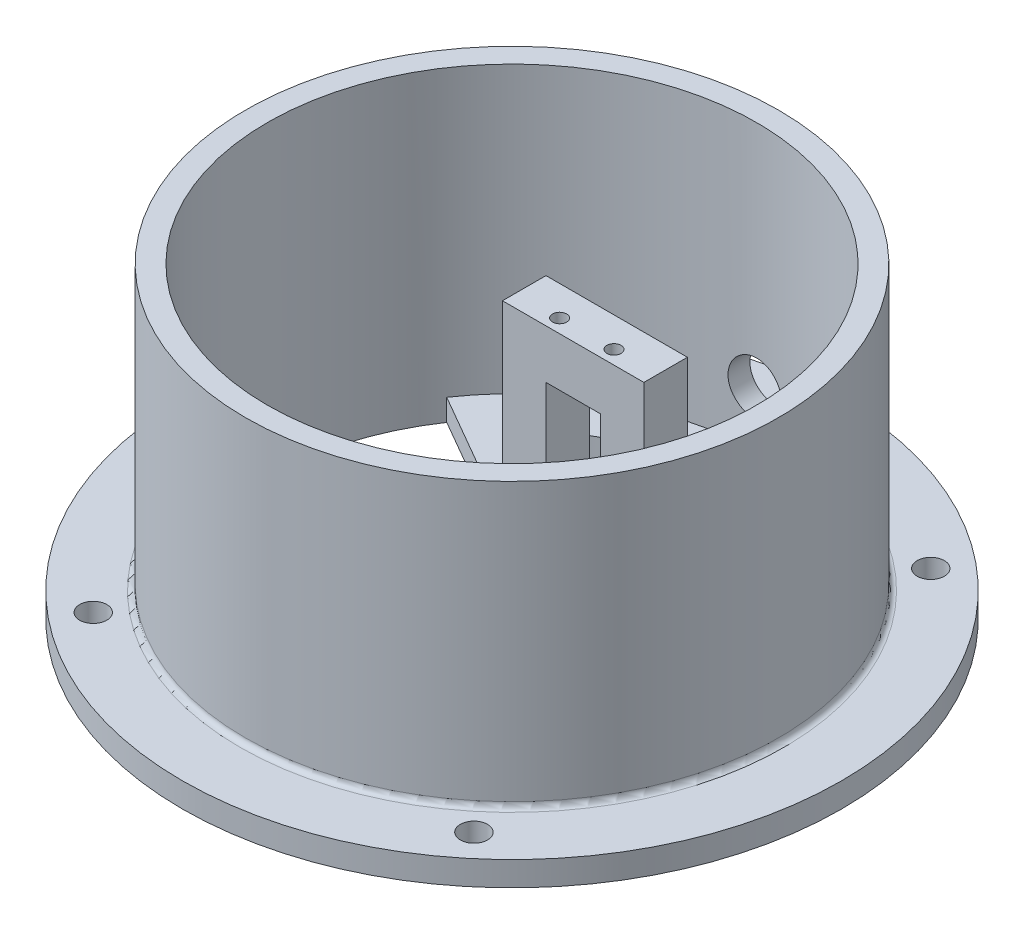
from build123d import *

# Parameters (mm, degrees)
SKETCH2_R           = 60.625
SKETCH2_R_2         = 45
BOSS_EXTRUDE1_DEPTH = 4.5
SKETCH3_R           = 49
SKETCH3_R_2         = 45
BOSS_EXTRUDE2_DEPTH = 52
SKETCH4_W           = 13.25
SKETCH4_H           = 8
SKETCH4_W_2         = 8
SKETCH4_H_2         = 38.5
BOSS_EXTRUDE3_DEPTH = 13
SKETCH5_W           = 10
SKETCH5_H           = 20
CUT_EXTRUDE1_DEPTH  = 26
SKETCH6_R           = 5
CUT_EXTRUDE2_DEPTH  = 50.375
SKETCH7_R           = 1.3
CUT_EXTRUDE3_DEPTH  = 7.2
BOSS_EXTRUDE4_DEPTH = 4
FILLET1_R           = 1
SKETCH9_R           = 2.5
CUT_EXTRUDE4_DEPTH  = 5.5000001


with BuildPart() as part:
    # Sketch2 → Boss-Extrude1 (new body)
    with BuildSketch(Plane(origin=(0, 0, 0), x_dir=(1, 0, 0), z_dir=(0, 1, 0))):
        Circle(SKETCH2_R)
        Circle(SKETCH2_R_2, mode=Mode.SUBTRACT)
    extrude(amount=BOSS_EXTRUDE1_DEPTH)

    # Sketch3 → Boss-Extrude2 (add)
    with BuildSketch(Plane(origin=(0, 4.5, 0), x_dir=(1, 0, 0), z_dir=(0, 1, 0))):
        Circle(SKETCH3_R)
        Circle(SKETCH3_R_2, mode=Mode.SUBTRACT)
    extrude(amount=BOSS_EXTRUDE2_DEPTH)

    # Sketch4 → Boss-Extrude3 (add, symmetric)
    with BuildSketch(Plane(origin=(0, 0, 0), x_dir=(0, 0, -1), z_dir=(1, 0, 0))):
        Polygon((-31.75, 30.5), (-45, 30.5), (-45, 17.25), align=None)
        with Locations((-38.375, 34.5)):
            Rectangle(SKETCH4_W, SKETCH4_H)
        with Locations((15.25, 19.25)):
            Rectangle(SKETCH4_W_2, SKETCH4_H_2)
    extrude(amount=BOSS_EXTRUDE3_DEPTH, both=True)

    # Sketch5 → Cut-Extrude1 (cut)
    with BuildSketch(Plane.XY):
        with Locations((0, 19.5)):
            Rectangle(SKETCH5_W, SKETCH5_H)
    extrude(amount=-CUT_EXTRUDE1_DEPTH, mode=Mode.SUBTRACT)

    # Sketch6 → Cut-Extrude2 (cut, through all)
    with BuildSketch(Plane.XY.offset(-11.25)):
        with Locations((0, 14)):
            Circle(SKETCH6_R)
    extrude(amount=-CUT_EXTRUDE2_DEPTH, mode=Mode.SUBTRACT)

    # Sketch7 → Cut-Extrude3 (cut)
    with BuildSketch(Plane(origin=(0, 38.5, 0), x_dir=(1, 0, 0), z_dir=(0, 1, 0))):
        with Locations((-5, 13.75)):
            Circle(SKETCH7_R)
        with Locations((5, 13.75)):
            Circle(SKETCH7_R)
        with Locations((-5, -34.25)):
            Circle(SKETCH7_R)
        with Locations((5, -34.25)):
            Circle(SKETCH7_R)
    extrude(amount=-CUT_EXTRUDE3_DEPTH, mode=Mode.SUBTRACT)

    # Sketch8 → Boss-Extrude4 (add)
    with BuildSketch(Plane.XZ):
        with BuildLine():
            Line((13, -11.25), (-13, -11.25))
            Line((-13, -11.25), (-37.248431585, -25.249838503))
            ThreePointArc((-37.248431585, -25.249838503), (0, -45), (37.248431585, -25.249838503))
            Line((37.248431585, -25.249838503), (13, -11.25))
        make_face()
        with BuildLine():
            Line((-19.516660498, -24.25), (-24.906460381, -27.361802413))
            ThreePointArc((-24.906460381, -27.361802413), (0, -37), (24.906460381, -27.361802413))
            Line((24.906460381, -27.361802413), (19.516660498, -24.25))
            Line((19.516660498, -24.25), (-19.516660498, -24.25))
        make_face(mode=Mode.SUBTRACT)
    extrude(amount=-BOSS_EXTRUDE4_DEPTH)

    # Fillet1
    fillet1_edges = [part.edges().sort_by_distance(p)[0] for p in [
        (-49, 4.5, 0),
    ]]
    fillet(fillet1_edges, radius=FILLET1_R)

    # Sketch9 → Cut-Extrude4 (cut, through all)
    with BuildSketch(Plane(origin=(0, 4.5, 0), x_dir=(1, 0, 0), z_dir=(0, 1, 0))):
        with Locations((35, 42)):
            Circle(SKETCH9_R)
        with Locations((35, -42)):
            Circle(SKETCH9_R)
        with Locations((-35, -42)):
            Circle(SKETCH9_R)
        with Locations((-35, 42)):
            Circle(SKETCH9_R)
    extrude(amount=-CUT_EXTRUDE4_DEPTH, mode=Mode.SUBTRACT)


solid = part.part
